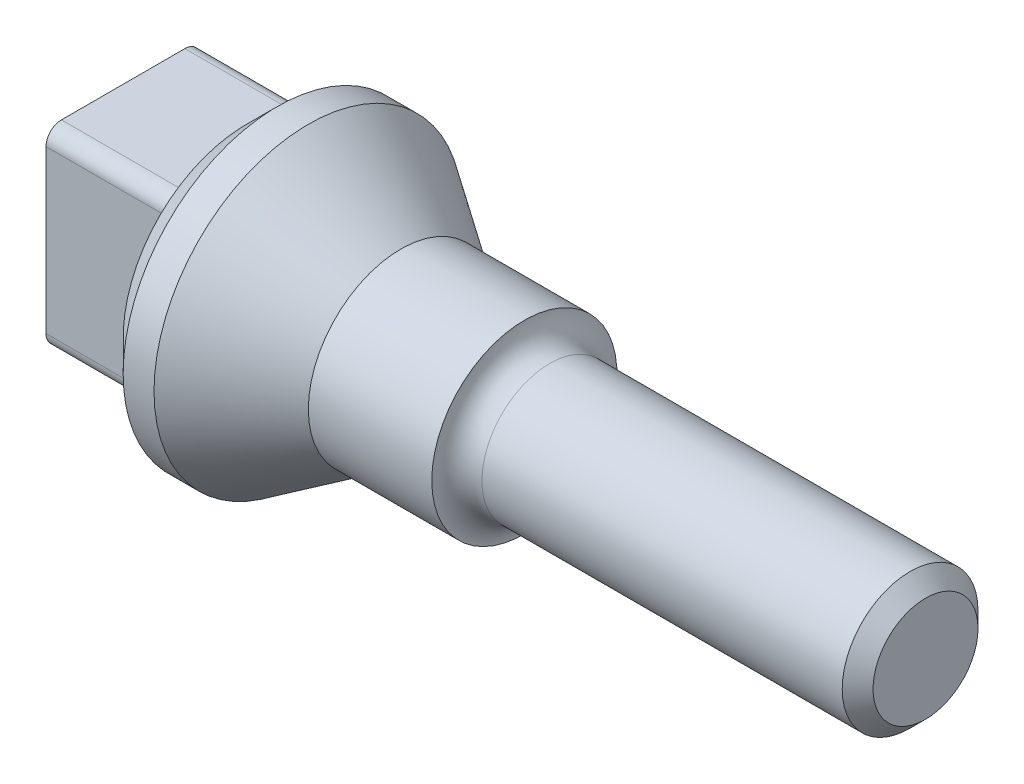
from build123d import *

# Parameters (mm, degrees)
SKETCH1_W           = 10
SKETCH1_H           = 50
SKETCH1_W_2         = 40
SKETCH1_H_2         = 30
SKETCH1_W_3         = 121.767034814
SKETCH1_H_3         = 22
SKETCH2_W           = 50
SKETCH2_H           = 62.449979984
BOSS_EXTRUDE1_DEPTH = 40
FILLET2_R           = 5
FILLET3_R           = 5
CHAMFER1_SIZE       = 5


with BuildPart() as part:
    # Sketch1 → Revolve1 (revolve)
    with BuildSketch(Plane.XY, mode=Mode.PRIVATE) as revolve1_sk:
        Polygon((10, 0), (0, 0), (0, -40), (10, -50), align=None)
        with Locations((15, -25)):
            Rectangle(SKETCH1_W, SKETCH1_H)
        Polygon((50, 0), (20, 0), (20, -50), (50, -30), align=None)
        with Locations((70, -15)):
            Rectangle(SKETCH1_W_2, SKETCH1_H_2)
        with BuildLine():
            Line((98.232965186, 0), (90, 0))
            Line((90, 0), (90, -30))
            ThreePointArc((90, -30), (92.493154306, -24.329399341), (98.232965186, -22))
            Line((98.232965186, -22), (98.232965186, 0))
        make_face()
        with Locations((159.116482593, -11)):
            Rectangle(SKETCH1_W_3, SKETCH1_H_3)
    revolve(revolve1_sk.sketch.rotate(Axis((0, 0, 0), (1, 0, 0)), 270), axis=Axis((0, 0, 0), (1, 0, 0)))

    # Sketch2 → Boss-Extrude1 (add)
    with BuildSketch(Plane.ZY):
        Rectangle(SKETCH2_W, SKETCH2_H)
    extrude(amount=BOSS_EXTRUDE1_DEPTH)

    # Fillet2
    fillet2_edges = [part.edges().sort_by_distance(p)[0] for p in [
        (-20, 31.224989992, 25),
    ]]
    fillet(fillet2_edges, radius=FILLET2_R)

    # Fillet3
    fillet3_edges = [part.edges().sort_by_distance(p)[0] for p in [
        (-20, -31.224989992, 25),
        (-20, 31.224989992, -25),
        (-20, -31.224989992, -25),
    ]]
    fillet(fillet3_edges, radius=FILLET3_R)

    # Chamfer1
    chamfer1_edges = [part.edges().sort_by_distance(p)[0] for p in [
        (220, 0, -22),
    ]]
    chamfer(chamfer1_edges, length=CHAMFER1_SIZE)


solid = part.part
